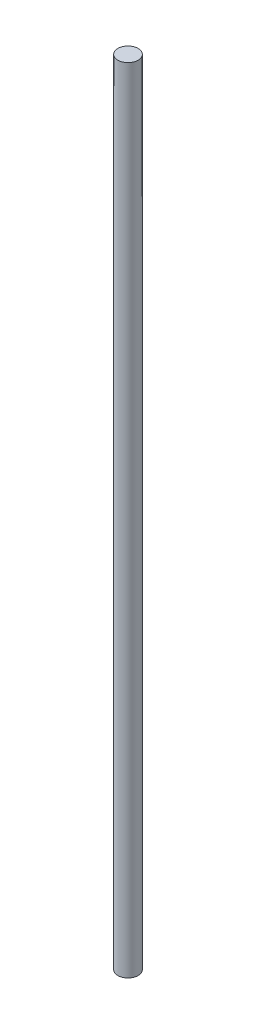
from build123d import *

# Parameters (mm, degrees)
IZIM1_R                     = 5
Y_KSEKLIK_EKSTR_ZYON1_DEPTH = 390


with BuildPart() as part:
    # Çizim1 → Yükseklik-Ekstrüzyon1 (new body)
    with BuildSketch(Plane(origin=(0, 0, 0), x_dir=(1, 0, 0), z_dir=(0, 1, 0))):
        Circle(IZIM1_R)
    extrude(amount=Y_KSEKLIK_EKSTR_ZYON1_DEPTH)


solid = part.part
